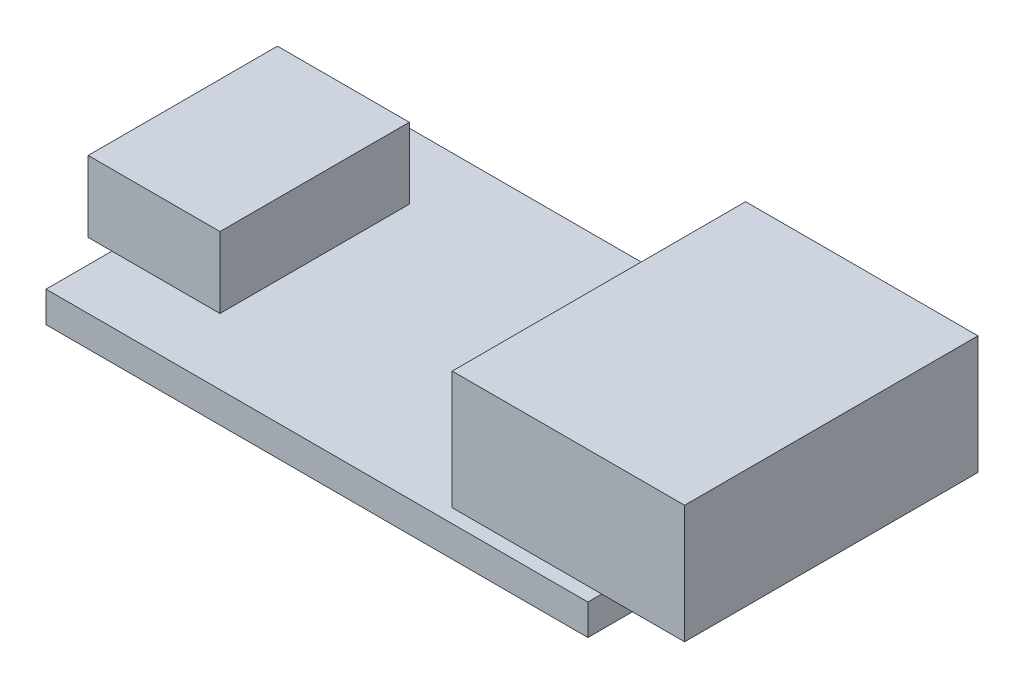
from build123d import *

# Parameters (mm, degrees)
SKETCH1_W           = 22.9
SKETCH1_H           = 13.57
BOSS_EXTRUDE1_DEPTH = 1.3
SKETCH1_3_W         = 9.82
SKETCH1_3_H         = 12.4
BOSS_EXTRUDE2_DEPTH = 5
SKETCH1_4_W         = 5.57
SKETCH1_4_H         = 8
BOSS_EXTRUDE3_DEPTH = 3


with BuildPart() as part:
    # Sketch1 → Boss-Extrude1 (new body)
    with BuildSketch(Plane(origin=(0, 0, 0), x_dir=(1, 0, 0), z_dir=(0, 1, 0))):
        with Locations((11.45, 0)):
            Rectangle(SKETCH1_W, SKETCH1_H)
    extrude(amount=-BOSS_EXTRUDE1_DEPTH)


with BuildPart() as body_2:
    # Sketch1_3 → Boss-Extrude2 (new body)
    with BuildSketch(Plane(origin=(0, 0, 0), x_dir=(1, 0, 0), z_dir=(0, 1, 0))):
        with Locations((21.49, 0)):
            Rectangle(SKETCH1_3_W, SKETCH1_3_H)
    extrude(amount=BOSS_EXTRUDE2_DEPTH)


with BuildPart() as body_3:
    # Sketch1_4 → Boss-Extrude3 (new body)
    with BuildSketch(Plane(origin=(0, 0, 0), x_dir=(1, 0, 0), z_dir=(0, 1, 0))):
        with Locations((1.78159017, 0)):
            Rectangle(SKETCH1_4_W, SKETCH1_4_H)
    extrude(amount=BOSS_EXTRUDE3_DEPTH)


solid = Compound([part.part, body_2.part, body_3.part])
